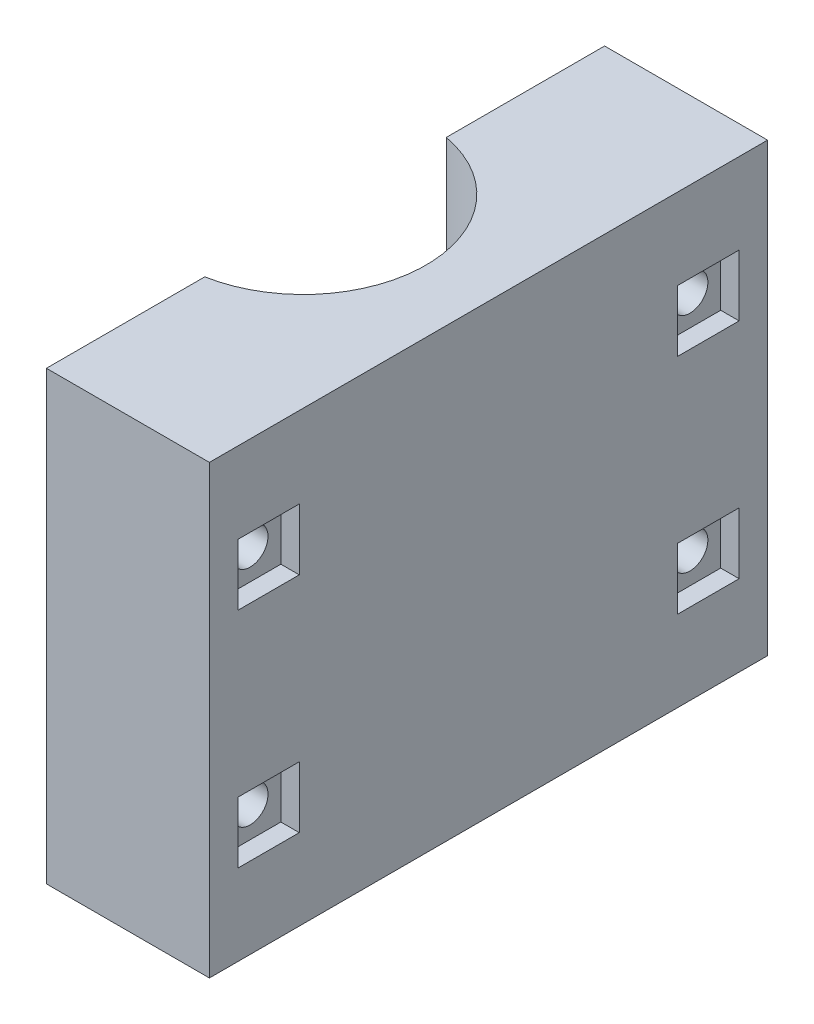
from build123d import *

# Parameters (mm, degrees)
SKETCH1_W           = 18.542
SKETCH1_H           = 63.5
BOSS_EXTRUDE1_DEPTH = 50.8
CUT_EXTRUDE1_DEPTH  = 50.8
SKETCH4_R           = 2.032
CUT_EXTRUDE3_DEPTH  = 18.542
CUT_EXTRUDE4_START  = -2.0955
SKETCH6_W           = 6.985
SKETCH6_H           = 6.985
CUT_EXTRUDE4_DEPTH  = 2.0955


with BuildPart() as part:
    # Sketch1 → Boss-Extrude1 (new body)
    with BuildSketch(Plane(origin=(0, 0, 0), x_dir=(1, 0, 0), z_dir=(0, 1, 0))):
        with Locations((9.271, 31.75)):
            Rectangle(SKETCH1_W, SKETCH1_H)
    extrude(amount=BOSS_EXTRUDE1_DEPTH)

    # Sketch2 → Cut-Extrude1 (cut)
    with BuildSketch(Plane(origin=(0, 50.8, 0), x_dir=(1, 0, 0), z_dir=(0, 1, 0))):
        with BuildLine():
            Line((-2.54, 45.72), (-2.54, 17.78))
            ThreePointArc((-2.54, 17.78), (11.43, 31.75), (-2.54, 45.72))
        make_face()
    extrude(amount=-CUT_EXTRUDE1_DEPTH, mode=Mode.SUBTRACT)

    # Sketch4 → Cut-Extrude3 (cut)
    with BuildSketch(Plane(origin=(18.542, 0, 0), x_dir=(0, 0, -1), z_dir=(1, 0, 0))):
        with Locations((56.769, 38.1)):
            Circle(SKETCH4_R)
        with Locations((56.769, 12.7)):
            Circle(SKETCH4_R)
        with Locations((6.731, 38.1)):
            Circle(SKETCH4_R)
        with Locations((6.731, 12.7)):
            Circle(SKETCH4_R)
    extrude(amount=-CUT_EXTRUDE3_DEPTH, mode=Mode.SUBTRACT)

    # Sketch6 → Cut-Extrude4 (cut)
    with BuildSketch(Plane(origin=(18.542, 0, 0), x_dir=(0, 0, -1), z_dir=(1, 0, 0)).offset(CUT_EXTRUDE4_START)):
        with Locations((56.769, 38.1)):
            Rectangle(SKETCH6_W, SKETCH6_H)
        with Locations((56.769, 12.7)):
            Rectangle(SKETCH6_W, SKETCH6_H)
        with Locations((6.731, 38.1)):
            Rectangle(SKETCH6_W, SKETCH6_H)
        with Locations((6.731, 12.7)):
            Rectangle(SKETCH6_W, SKETCH6_H)
    extrude(amount=CUT_EXTRUDE4_DEPTH, mode=Mode.SUBTRACT)


solid = part.part
